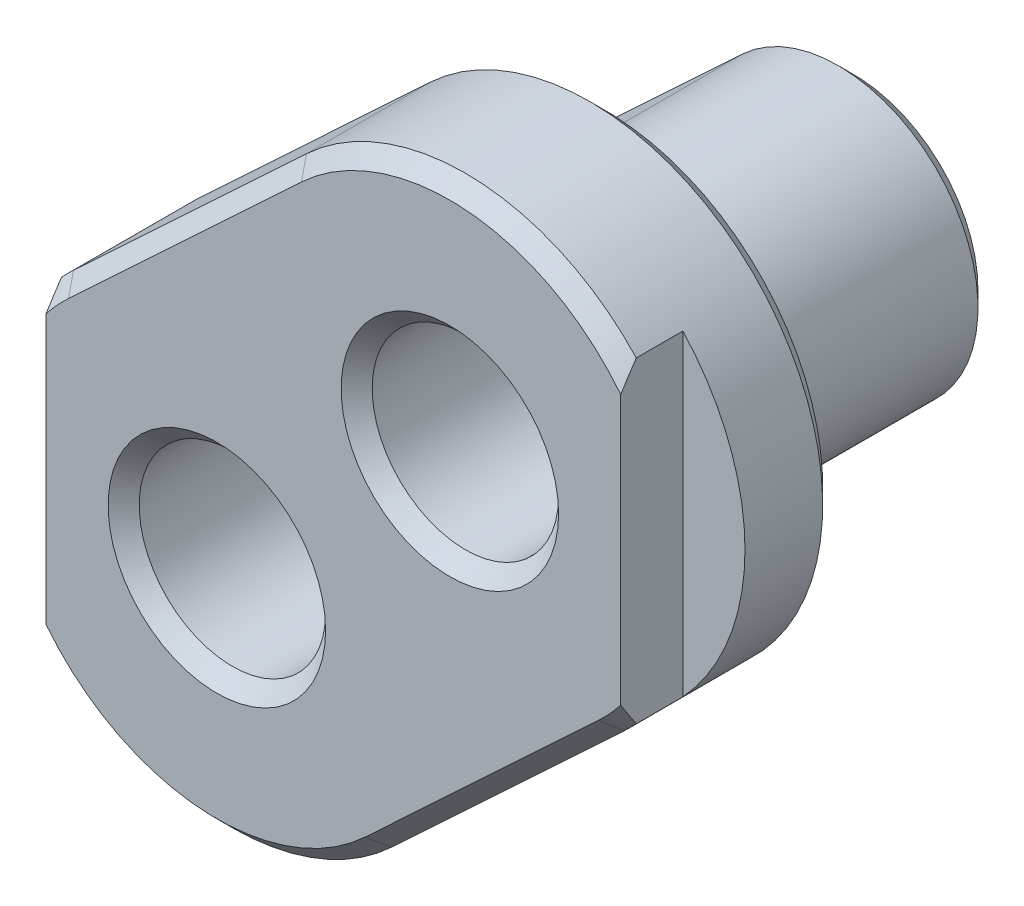
from build123d import *

# Parameters (mm, degrees)
EXTRUDE_1_DEPTH     = 16
EXTRUDE_2_DEPTH     = 10
CUT_EXTRUDE_1_DEPTH = 4
SKETCH_4_R          = 6
CUT_EXTRUDE_2_DEPTH = 27
CHAMFER_1_SIZE      = 1


with BuildPart() as part:
    # 草图1 → 凸台-拉伸1 (new body)
    with BuildSketch(Plane.XY):
        with BuildLine():
            Line((6.140864253, -6.579497414), (21.140864253, 7.420502586))
            ThreePointArc((21.140864253, 7.420502586), (21.579497414, 20.140864253), (8.859135747, 20.579497414))
            Line((8.859135747, 20.579497414), (-6.140864253, 6.579497414))
            ThreePointArc((-6.140864253, 6.579497414), (-6.579497414, -6.140864253), (6.140864253, -6.579497414))
        make_face()
    extrude(amount=EXTRUDE_1_DEPTH)

    # 草图2 → 凸台-拉伸2 (add)
    with BuildSketch(Plane.XY.offset(16)):
        with BuildLine():
            Line((10.234773755, -10.965829024), (25.234773755, 3.034170976))
            ThreePointArc((25.234773755, 3.034170976), (25.965829024, 24.234773755), (4.765226245, 24.965829024))
            Line((4.765226245, 24.965829024), (-10.234773755, 10.965829024))
            ThreePointArc((-10.234773755, 10.965829024), (-10.965829024, -10.234773755), (10.234773755, -10.965829024))
        make_face()
    extrude(amount=EXTRUDE_2_DEPTH)

    # 草图3 → 切除-拉伸1 (cut)
    with BuildSketch(Plane.XY.offset(26)):
        with BuildLine():
            Line((26, 24.198039027), (26, 3.801960973))
            ThreePointArc((26, 3.801960973), (30, 14), (26, 24.198039027))
        make_face()
        with BuildLine():
            Line((-11, 10.198039027), (-11, -10.198039027))
            ThreePointArc((-11, -10.198039027), (-15, 0), (-11, 10.198039027))
        make_face()
    extrude(amount=-CUT_EXTRUDE_1_DEPTH, mode=Mode.SUBTRACT)

    # 草图4 → 切除-拉伸2 (cut, through all)
    with BuildSketch(Plane(origin=(0, 0, 0), x_dir=(-1, 0, 0), z_dir=(0, 0, -1))):
        Circle(SKETCH_4_R)
        with Locations((-15, 14)):
            Circle(SKETCH_4_R)
    extrude(amount=-CUT_EXTRUDE_2_DEPTH, mode=Mode.SUBTRACT)

    # 倒角1
    chamfer_1_edges = [part.edges().sort_by_distance(p)[0] for p in [
        (-10.965829024, -10.234773755, 16),
        (17.734773755, -3.965829024, 16),
        (25.965829024, 24.234773755, 16),
        (-2.734773755, 17.965829024, 16),
        (-10.624324895, 10.588848876, 26),
        (17.734773755, -3.965829024, 26),
        (25.624324895, 3.411151124, 26),
        (-2.734773755, 17.965829024, 26),
        (-0.542003848, -14.990204529, 26),
        (15.542003848, 28.990204529, 26),
        (1.359135747, 13.579497414, 0),
        (6, 0, 26),
        (6, 0, 0),
        (21, 14, 26),
        (21, 14, 0),
        (21.579497414, 20.140864253, 0),
        (13.640864253, 0.420502586, 0),
        (-6.579497414, -6.140864253, 0),
    ]]
    chamfer(chamfer_1_edges, length=CHAMFER_1_SIZE)


solid = part.part
